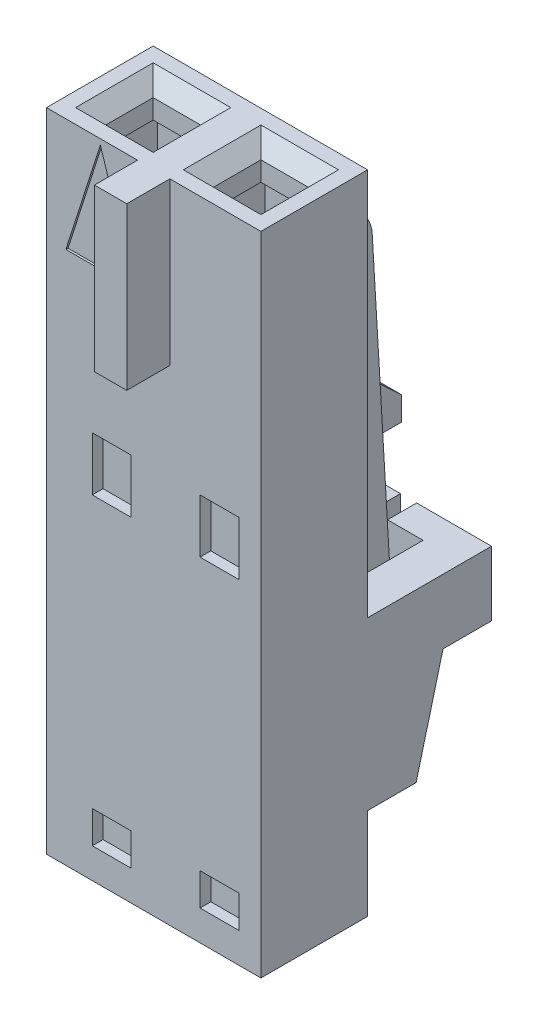
from build123d import *

# Parameters (mm, degrees)
SKETCH1_W            = 5.0546
SKETCH1_H            = 15.24
BOSS_EXTRUDE1_DEPTH  = 2.514600001
CUT_EXTRUDE1_REACH   = 2.051
BOSS_EXTRUDE2_DEPTH  = 2.4384
CHAMFER1_SIZE        = 3.689417857
CHAMFER1_SIZE2       = 0.617363155
BOSS_EXTRUDE3_DEPTH  = 1.121675474
DRAFT1_ANGLE         = 3.38
FILLET1_R            = 0.8128
CUT_EXTRUDE2_DEPTH   = 0.8382
CUT_EXTRUDE3_DEPTH   = 0.8382
BOSS_EXTRUDE4_REACH  = 6.826
SKETCH7_W            = 2.032
SKETCH7_H            = 0.5588
DRAFT2_ANGLE         = 43.044366599
SKETCH8_W            = 0.9271
SKETCH8_H            = 3.937
BOSS_EXTRUDE5_DEPTH  = 1.778
SKETCH9_W            = 0.9271
SKETCH9_H            = 3.937
BOSS_EXTRUDE6_DEPTH  = 1.778
SKETCH10_W           = 0.9271
SKETCH10_H           = 1.524
BOSS_EXTRUDE7_DEPTH  = 1.143
SKETCH11_W           = 0.9271
SKETCH11_H           = 1.524
BOSS_EXTRUDE8_DEPTH  = 1.143
SKETCH12_W           = 0.6858
SKETCH12_H           = 1.524
BOSS_EXTRUDE9_DEPTH  = 0.8382
SKETCH13_W           = 0.6858
SKETCH13_H           = 1.524
BOSS_EXTRUDE10_DEPTH = 0.8382
DRAFT3_ANGLE         = 14.743562836
DRAFT4_ANGLE         = 14.743562836
CUT_EXTRUDE4_DEPTH   = 0.762
CUT_EXTRUDE5_DEPTH   = 0.762
CUT_EXTRUDE6_DEPTH   = 0.762
SKETCH17_W           = 0.762
SKETCH17_H           = 3.81
BOSS_EXTRUDE11_DEPTH = 1.016
SKETCH18_W           = 0.9144
SKETCH18_H           = 1.27
CUT_EXTRUDE7_DEPTH   = 0.254
SKETCH19_W           = 0.9144
SKETCH19_H           = 0.762
CUT_EXTRUDE8_DEPTH   = 0.254
SKETCH20_W           = 0.9144
SKETCH20_H           = 1.27
CUT_EXTRUDE9_DEPTH   = 0.254
SKETCH21_W           = 0.9144
SKETCH21_H           = 0.762
CUT_EXTRUDE10_DEPTH  = 0.254
SKETCH22_W           = 1.8542
SKETCH22_H           = 1.778
CUT_EXTRUDE11_DEPTH  = 8.636
SKETCH23_W           = 1.8542
SKETCH23_H           = 1.778
CUT_EXTRUDE12_DEPTH  = 8.636
CHAMFER2_SIZE        = 0.0762
CHAMFER2_SIZE2       = 0.254
CHAMFER3_SIZE        = 0.2159
CHAMFER3_SIZE2       = 0.254
SKETCH24_W           = 1.27
SKETCH24_H           = 0.3683
CUT_EXTRUDE13_DEPTH  = 1.016
SKETCH25_W           = 1.27
SKETCH25_H           = 0.3683
CUT_EXTRUDE14_DEPTH  = 1.016
SKETCH26_W           = 1.4224
SKETCH26_H           = 1.6256
CUT_EXTRUDE15_DEPTH  = 5.7912
SKETCH27_W           = 1.4224
SKETCH27_H           = 1.6256
CUT_EXTRUDE16_DEPTH  = 5.7912
SKETCH28_W           = 1.1176
SKETCH28_H           = 1.1176
CUT_EXTRUDE17_DEPTH  = 1.8128
SKETCH29_W           = 1.1176
SKETCH29_H           = 1.1176
CUT_EXTRUDE18_DEPTH  = 1.8128
CHAMFER4_SIZE        = 0.3556
CHAMFER5_SIZE        = 0.3556


with BuildPart() as part:
    # Sketch1 → Boss-Extrude1 (new body)
    with BuildSketch(Plane.XY.offset(1.2573)):
        Rectangle(SKETCH1_W, SKETCH1_H)
    extrude(amount=-BOSS_EXTRUDE1_DEPTH)

    # Sketch2 → Cut-Extrude1 (cut, up to next)
    with BuildSketch(Plane(origin=(0, 0, 1.2065), x_dir=(-1, 0, 0), z_dir=(0, 0, -1)), mode=Mode.PRIVATE) as cut_extrude1_sk1:
        Polygon((0.4445, 4.953), (2.0701, 4.953), (1.2573, 7.493), align=None)
    cut_extrude1_tool1 = extrude(cut_extrude1_sk1.sketch, amount=-CUT_EXTRUDE1_REACH, mode=Mode.PRIVATE) & part.part
    add(cut_extrude1_tool1.solids().sort_by_distance((-1.2573, 5.799667, 1.2065))[0], mode=Mode.SUBTRACT)

    # Sketch3 → Boss-Extrude2 (add)
    with BuildSketch(Plane(origin=(-1.2192, 0, 0), x_dir=(0, -1, 0), z_dir=(-1, 0, 0))):
        with BuildLine():
            Line((5.207, -2.434484307), (-4.412170374, -1.866369791))
            ThreePointArc((-4.412170374, -1.866369791), (-4.698867419, -1.553110903), (-4.394200001, -1.2573))
            Line((-4.394200001, -1.2573), (-5.715, -1.2573))
            Line((-5.715, -1.2573), (-5.715, -3.056624526))
            Line((-5.715, -3.056624526), (3.048, -3.056624526))
            Line((3.048, -3.056624526), (3.429, -3.056624526))
            Line((3.429, -3.056624526), (3.683, -3.056624526))
            Line((3.683, -3.056624526), (4.191, -3.056624526))
            Line((4.191, -3.056624526), (4.445, -3.056624526))
            Line((4.445, -3.056624526), (4.953, -3.056624526))
            Line((4.953, -3.056624526), (5.207, -3.056624526))
            Line((5.207, -3.056624526), (5.207, -2.434484307))
        make_face()
    extrude(amount=-BOSS_EXTRUDE2_DEPTH)

    # Chamfer1
    chamfer1_edges = [part.edges().sort_by_distance(p)[0] for p in [
        (0, -5.207, -2.434484307),
    ]]
    chamfer1_side = [part.faces().sort_by_distance(p)[0] for p in [
        (0, -0.397414813, -2.150427049),
    ]]
    chamfer(chamfer1_edges, length=CHAMFER1_SIZE, length2=CHAMFER1_SIZE2, reference=chamfer1_side[0])

    # Sketch4 → Boss-Extrude3 (add)
    with BuildSketch(Plane(origin=(0, 0, -3.056624526), x_dir=(-1, 0, 0), z_dir=(0, 0, -1))):
        Polygon((1.2192, -3.683000003), (1.2192, -4.191000003), (1.2192, -4.445000003), (1.2192, -4.953000003), (1.2192, -5.207000003), (0.381, -5.207000003), (-0.381, -5.207000003), (-1.2192, -5.207000003), (-1.2192, -4.953000003), (-1.2192, -4.445000003), (-1.2192, -4.191000003), (-1.2192, -3.683000003), (-1.2192, -3.429000003), (-1.2192, -3.048000003), (-1.2192, -1.524000003), (-0.381, -1.524000003), (0.381, -1.524000003), (1.2192, -1.524000003), (1.2192, -3.048000003), (1.2192, -3.429000003), align=None)
    extrude(amount=BOSS_EXTRUDE3_DEPTH)

    # Draft1
    draft1_faces = [part.faces().sort_by_distance(p)[0] for p in [
        (0, 2.095499999, -3.056624526),
    ]]
    draft(draft1_faces, Plane(origin=(1.2192, -1.524000003, -4.1783), x_dir=(1, 0, 0), z_dir=(0, 1, 0)), DRAFT1_ANGLE)

    # Fillet1
    fillet1_edges = [part.edges().sort_by_distance(p)[0] for p in [
        (0, 5.715, -2.629084434),
    ]]
    fillet(fillet1_edges, radius=FILLET1_R)

    # Sketch5 → Cut-Extrude2 (cut)
    with BuildSketch(Plane.ZY.offset(1.2192)):
        Polygon((-4.1783, -1.523999999), (-4.1783, -3.048), (-4.1783, -3.429), (-4.1783, -3.683), (-4.1783, -4.191), (-4.1783, -4.445), (-4.1783, -4.953), (-4.1783, -5.207), (-3.051847462, -5.207), (-2.562432966, -3.048), (-3.146632966, -3.048), (-3.056624525, -1.523999999), align=None)
    extrude(amount=-CUT_EXTRUDE2_DEPTH, mode=Mode.SUBTRACT)

    # Sketch6 → Cut-Extrude3 (cut)
    with BuildSketch(Plane(origin=(1.2192, 0, 0), x_dir=(0, 0, -1), z_dir=(1, 0, 0))):
        Polygon((4.1783, -3.429), (4.1783, -3.048), (4.1783, -1.524000001), (3.056624525, -1.524000001), (3.146632966, -3.048), (2.562432966, -3.048), (3.051847462, -5.207), (4.1783, -5.207), (4.1783, -4.953), (4.1783, -4.445), (4.1783, -4.191), (4.1783, -3.683), align=None)
    extrude(amount=-CUT_EXTRUDE3_DEPTH, mode=Mode.SUBTRACT)

    # Sketch7 → Boss-Extrude4 (add, up to next)
    with BuildSketch(Plane(origin=(0, 0, -3.5687), x_dir=(-1, 0, 0), z_dir=(0, 0, -1)), mode=Mode.PRIVATE) as boss_extrude4_sk1:
        with Locations((0, 0.8382)):
            Rectangle(SKETCH7_W, SKETCH7_H)
    boss_extrude4_tool1 = extrude(boss_extrude4_sk1.sketch, amount=-BOSS_EXTRUDE4_REACH, mode=Mode.PRIVATE) - part.part
    add(boss_extrude4_tool1.solids().sort_by_distance((0, 0.8382, -3.5687))[0])

    # Draft2
    draft2_faces = [part.faces().sort_by_distance(p)[0] for p in [
        (0, 1.1176, -3.234654948),
    ]]
    draft(draft2_faces, Plane(origin=(0, 0, -3.5687), x_dir=(-1, 0, 0), z_dir=(0, 0, -1)), DRAFT2_ANGLE)

    # Sketch8 → Boss-Extrude5 (add)
    with BuildSketch(Plane(origin=(0, 0, -1.257300001), x_dir=(-1, 0, 0), z_dir=(0, 0, -1))):
        with Locations((-2.06375, -3.4925)):
            Rectangle(SKETCH8_W, SKETCH8_H)
    extrude(amount=BOSS_EXTRUDE5_DEPTH)

    # Sketch9 → Boss-Extrude6 (add)
    with BuildSketch(Plane(origin=(0, 0, -1.257300001), x_dir=(-1, 0, 0), z_dir=(0, 0, -1))):
        with Locations((2.06375, -3.4925)):
            Rectangle(SKETCH9_W, SKETCH9_H)
    extrude(amount=BOSS_EXTRUDE6_DEPTH)

    # Sketch10 → Boss-Extrude7 (add)
    with BuildSketch(Plane(origin=(0, 0, -3.035300001), x_dir=(-1, 0, 0), z_dir=(0, 0, -1))):
        with Locations((2.06375, -2.286)):
            Rectangle(SKETCH10_W, SKETCH10_H)
    extrude(amount=BOSS_EXTRUDE7_DEPTH)

    # Sketch11 → Boss-Extrude8 (add)
    with BuildSketch(Plane(origin=(0, 0, -3.035300001), x_dir=(-1, 0, 0), z_dir=(0, 0, -1))):
        with Locations((-2.06375, -2.286)):
            Rectangle(SKETCH11_W, SKETCH11_H)
    extrude(amount=BOSS_EXTRUDE8_DEPTH)

    # Sketch12 → Boss-Extrude9 (add)
    with BuildSketch(Plane.ZY.offset(-1.6002)):
        with Locations((-3.8354, -2.286)):
            Rectangle(SKETCH12_W, SKETCH12_H)
    extrude(amount=BOSS_EXTRUDE9_DEPTH)

    # Sketch13 → Boss-Extrude10 (add)
    with BuildSketch(Plane(origin=(-1.6002, 0, 0), x_dir=(0, 0, -1), z_dir=(1, 0, 0))):
        with Locations((3.8354, -2.286)):
            Rectangle(SKETCH13_W, SKETCH13_H)
    extrude(amount=BOSS_EXTRUDE10_DEPTH)

    # Draft3
    draft3_faces = [part.faces().sort_by_distance(p)[0] for p in [
        (-2.06375, -4.2545, -3.035300001),
    ]]
    draft(draft3_faces, Plane(origin=(-2.5273, -3.048, -4.178300001), x_dir=(-1, 0, 0), z_dir=(0, -1, 0)), DRAFT3_ANGLE)

    # Draft4
    draft4_faces = [part.faces().sort_by_distance(p)[0] for p in [
        (2.06375, -4.2545, -3.035300001),
    ]]
    draft(draft4_faces, Plane(origin=(1.6002, -3.048, -4.178300001), x_dir=(0, 0, -1), z_dir=(0, -1, 0)), DRAFT4_ANGLE)

    # Sketch14 → Cut-Extrude4 (cut)
    with BuildSketch(Plane.ZY.offset(0.381)):
        Polygon((-4.1783, -3.429), (-3.9878, -3.048), (-4.1783, -3.048), align=None)
    extrude(amount=-CUT_EXTRUDE4_DEPTH, mode=Mode.SUBTRACT)

    # Sketch15 → Cut-Extrude5 (cut)
    with BuildSketch(Plane.ZY.offset(0.381)):
        Polygon((-4.1783, -4.191), (-3.9243, -4.064), (-3.9243, -3.81), (-4.1783, -3.683), align=None)
    extrude(amount=-CUT_EXTRUDE5_DEPTH, mode=Mode.SUBTRACT)

    # Sketch16 → Cut-Extrude6 (cut)
    with BuildSketch(Plane.ZY.offset(0.381)):
        Polygon((-4.1783, -4.953), (-3.9243, -4.826), (-3.9243, -4.572), (-4.1783, -4.445), align=None)
    extrude(amount=-CUT_EXTRUDE6_DEPTH, mode=Mode.SUBTRACT)

    # Sketch17 → Boss-Extrude11 (add)
    with BuildSketch(Plane.XY.offset(1.2573)):
        with Locations((0, 5.715)):
            Rectangle(SKETCH17_W, SKETCH17_H)
    extrude(amount=BOSS_EXTRUDE11_DEPTH)

    # Sketch18 → Cut-Extrude7 (cut)
    with BuildSketch(Plane.XY.offset(1.2573)):
        with Locations((1.5494, 0.889)):
            Rectangle(SKETCH18_W, SKETCH18_H)
    extrude(amount=-CUT_EXTRUDE7_DEPTH, mode=Mode.SUBTRACT)

    # Sketch19 → Cut-Extrude8 (cut)
    with BuildSketch(Plane.XY.offset(1.2573)):
        with Locations((1.5494, -6.5278)):
            Rectangle(SKETCH19_W, SKETCH19_H)
    extrude(amount=-CUT_EXTRUDE8_DEPTH, mode=Mode.SUBTRACT)

    # Sketch20 → Cut-Extrude9 (cut)
    with BuildSketch(Plane.XY.offset(1.2573)):
        with Locations((-0.9906, 0.889)):
            Rectangle(SKETCH20_W, SKETCH20_H)
    extrude(amount=-CUT_EXTRUDE9_DEPTH, mode=Mode.SUBTRACT)

    # Sketch21 → Cut-Extrude10 (cut)
    with BuildSketch(Plane.XY.offset(1.2573)):
        with Locations((-0.9906, -6.5278)):
            Rectangle(SKETCH21_W, SKETCH21_H)
    extrude(amount=-CUT_EXTRUDE10_DEPTH, mode=Mode.SUBTRACT)

    # Sketch22 → Cut-Extrude11 (cut)
    with BuildSketch(Plane.XZ.offset(7.62)):
        with Locations((-1.27, 0)):
            Rectangle(SKETCH22_W, SKETCH22_H)
    extrude(amount=-CUT_EXTRUDE11_DEPTH, mode=Mode.SUBTRACT)

    # Sketch23 → Cut-Extrude12 (cut)
    with BuildSketch(Plane.XZ.offset(7.62)):
        with Locations((1.27, 0)):
            Rectangle(SKETCH23_W, SKETCH23_H)
    extrude(amount=-CUT_EXTRUDE12_DEPTH, mode=Mode.SUBTRACT)

    # Chamfer2
    chamfer2_edges = [part.edges().sort_by_distance(p)[0] for p in [
        (-0.3429, 1.016, 0),
        (-1.27, 1.016, -0.889),
        (-2.1971, 1.016, 0),
        (-1.27, 1.016, 0.889),
    ]]
    chamfer2_side = [part.faces().sort_by_distance(p)[0] for p in [
        (-1.27, 1.016, 0),
    ]]
    chamfer(chamfer2_edges, length=CHAMFER2_SIZE, length2=CHAMFER2_SIZE2, reference=chamfer2_side[0])

    # Chamfer3
    chamfer3_edges = [part.edges().sort_by_distance(p)[0] for p in [
        (1.27, 1.016, 0.889),
        (2.1971, 1.016, 0),
        (1.27, 1.016, -0.889),
        (0.3429, 1.016, 0),
    ]]
    chamfer3_side = [part.faces().sort_by_distance(p)[0] for p in [
        (1.27, 1.016, 0),
    ]]
    chamfer(chamfer3_edges, length=CHAMFER3_SIZE, length2=CHAMFER3_SIZE2, reference=chamfer3_side[0])

    # Sketch24 → Cut-Extrude13 (cut)
    with BuildSketch(Plane.XZ.offset(7.62)):
        with Locations((-1.2827, -1.07315)):
            Rectangle(SKETCH24_W, SKETCH24_H)
    extrude(amount=-CUT_EXTRUDE13_DEPTH, mode=Mode.SUBTRACT)

    # Sketch25 → Cut-Extrude14 (cut)
    with BuildSketch(Plane.XZ.offset(7.62)):
        with Locations((1.2573, -1.07315)):
            Rectangle(SKETCH25_W, SKETCH25_H)
    extrude(amount=-CUT_EXTRUDE14_DEPTH, mode=Mode.SUBTRACT)

    # Sketch26 → Cut-Extrude15 (cut)
    with BuildSketch(Plane.XZ.offset(-1.016)):
        with Locations((-1.27, 0)):
            Rectangle(SKETCH26_W, SKETCH26_H)
    extrude(amount=-CUT_EXTRUDE15_DEPTH, mode=Mode.SUBTRACT)

    # Sketch27 → Cut-Extrude16 (cut)
    with BuildSketch(Plane.XZ.offset(-1.016)):
        with Locations((1.27, 0)):
            Rectangle(SKETCH27_W, SKETCH27_H)
    extrude(amount=-CUT_EXTRUDE16_DEPTH, mode=Mode.SUBTRACT)

    # Sketch28 → Cut-Extrude17 (cut, through all)
    with BuildSketch(Plane.XZ.offset(-6.8072)):
        with Locations((1.27, 0)):
            Rectangle(SKETCH28_W, SKETCH28_H)
    extrude(amount=-CUT_EXTRUDE17_DEPTH, mode=Mode.SUBTRACT)

    # Sketch29 → Cut-Extrude18 (cut, through all)
    with BuildSketch(Plane.XZ.offset(-6.8072)):
        with Locations((-1.27, 0)):
            Rectangle(SKETCH29_W, SKETCH29_H)
    extrude(amount=-CUT_EXTRUDE18_DEPTH, mode=Mode.SUBTRACT)

    # Chamfer4
    chamfer4_edges = [part.edges().sort_by_distance(p)[0] for p in [
        (1.27, 7.62, -0.5588),
        (0.7112, 7.62, 0),
        (1.27, 7.62, 0.5588),
        (1.8288, 7.62, 0),
    ]]
    chamfer(chamfer4_edges, length=CHAMFER4_SIZE)

    # Chamfer5
    chamfer5_edges = [part.edges().sort_by_distance(p)[0] for p in [
        (-0.7112, 7.62, 0),
        (-1.27, 7.62, -0.5588),
        (-1.8288, 7.62, 0),
        (-1.27, 7.62, 0.5588),
    ]]
    chamfer(chamfer5_edges, length=CHAMFER5_SIZE)


solid = part.part
